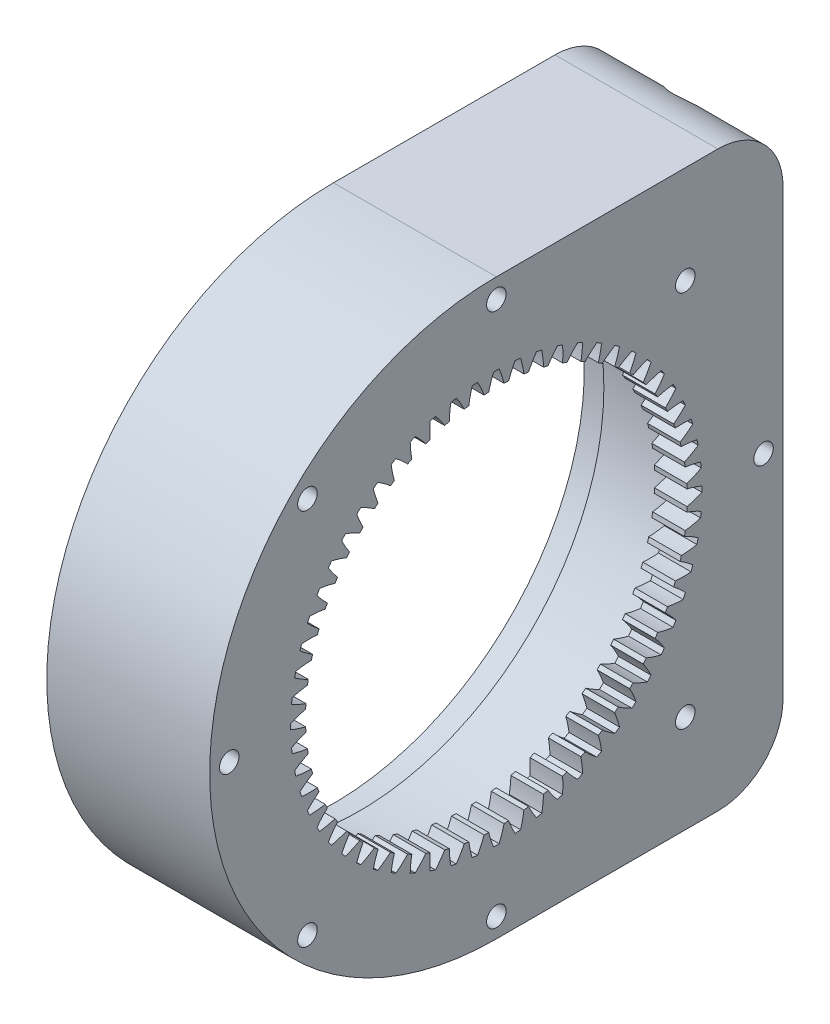
from build123d import *

# Parameters (mm, degrees)
BASPROSKE_W         = 5
BASPROSKE_H         = 14.71
TOOTHCUT_DEPTH      = 63.42595614
TEETHCUTS_COUNT     = 60
SKETCH4_R           = 44
SKETCH4_R_2         = 38.5
BOSS_EXTRUDE3_DEPTH = 20
BOSS_EXTRUDE5_DEPTH = 25
BOSS_EXTRUDE6_DEPTH = 25
FILLET1_R           = 10
SKETCH14_R          = 38.5
SKETCH14_R_2        = 37.5
BOSS_EXTRUDE7_DEPTH = 16
SKETCH15_R          = 1.5
CUT_EXTRUDE1_DEPTH  = 68.059674917
CIRPATTERN1_COUNT   = 8
SKETCH16_R          = 4.25
CUT_EXTRUDE2_DEPTH  = 20


with BuildPart() as part:
    # BasProSke → Base-Revolve (revolve)
    with BuildSketch(Plane(origin=(0, 0, 0), x_dir=(1, 0, 0), z_dir=(0, 1, 0)), mode=Mode.PRIVATE) as base_revolve_sk:
        with Locations((2.5, 36.645)):
            Rectangle(BASPROSKE_W, BASPROSKE_H)
    revolve(base_revolve_sk.sketch.rotate(Axis((-10, 0, 0), (1, 0, 0)), 180), axis=Axis((-10, 0, 0), (1, 0, 0)))

    # TooCutSke → ToothCut (cut, through all)
    with BuildSketch(Plane(origin=(0, 0, 0), x_dir=(0, 0, -1), z_dir=(1, 0, 0))):
        with BuildLine():
            ThreePointArc((1.17756088, 29.240898815), (0.846801732, 30.416008239), (0.422504134, 31.560672086))
            ThreePointArc((0.422504134, 31.560672086), (0, 31.5635), (-0.422504134, 31.560672086))
            ThreePointArc((-0.422504134, 31.560672086), (-0.846801732, 30.416008239), (-1.17756088, 29.240898815))
            ThreePointArc((-1.17756088, 29.240898815), (0, 29.2646), (1.17756088, 29.240898815))
        make_face()
    toothcut = extrude(amount=TOOTHCUT_DEPTH, mode=Mode.SUBTRACT)

    # TeethCuts: ToothCut ×60 about axis
    teethcuts_axis = Axis((0, 0, 0), (1, 0, 0))
    for i in range(1, TEETHCUTS_COUNT):
        add(toothcut.rotate(teethcuts_axis, i * 360 / TEETHCUTS_COUNT), mode=Mode.SUBTRACT)

    # Sketch4 → Boss-Extrude3 (add)
    with BuildSketch(Plane.ZY):
        Circle(SKETCH4_R)
        Circle(SKETCH4_R_2, mode=Mode.SUBTRACT)
    extrude(amount=BOSS_EXTRUDE3_DEPTH)

    # Sketch7 → Boss-Extrude5 (add)
    with BuildSketch(Plane(origin=(5, 0, 0), x_dir=(0, 0, -1), z_dir=(1, 0, 0))):
        with BuildLine():
            Line((0, 44), (44, 44))
            Line((44, 44), (44, 0))
            ThreePointArc((44, 0), (31.112698372, 31.112698372), (0, 44))
        make_face()
    extrude(amount=-BOSS_EXTRUDE5_DEPTH)

    # Sketch10 → Boss-Extrude6 (add)
    with BuildSketch(Plane(origin=(5, 0, 0), x_dir=(0, 0, -1), z_dir=(1, 0, 0))):
        with BuildLine():
            Line((0, -44), (44, -44))
            Line((44, -44), (44, 0))
            ThreePointArc((44, 0), (31.112698372, -31.112698372), (0, -44))
        make_face()
    extrude(amount=-BOSS_EXTRUDE6_DEPTH)

    # Fillet1
    fillet1_edges = [part.edges().sort_by_distance(p)[0] for p in [
        (-7.5, 44, -44),
        (-7.5, -44, -44),
    ]]
    fillet(fillet1_edges, radius=FILLET1_R)

    # Sketch14 → Boss-Extrude7 (add)
    with BuildSketch(Plane.ZY):
        Circle(SKETCH14_R)
        Circle(SKETCH14_R_2, mode=Mode.SUBTRACT)
    extrude(amount=BOSS_EXTRUDE7_DEPTH)

    # Sketch15 → Cut-Extrude1 (cut, through all)
    with BuildSketch(Plane.ZY.offset(20)):
        with Locations((-41, 0)):
            Circle(SKETCH15_R)
    cut_extrude1 = extrude(amount=-CUT_EXTRUDE1_DEPTH, mode=Mode.SUBTRACT)

    # CirPattern1: Cut-Extrude1 ×8 about axis
    cirpattern1_axis = Axis((0, 0, 0), (1, 0, 0))
    for i in range(1, CIRPATTERN1_COUNT):
        add(cut_extrude1.rotate(cirpattern1_axis, i * 360 / CIRPATTERN1_COUNT), mode=Mode.SUBTRACT)

    # Sketch16 → Cut-Extrude2 (cut)
    with BuildSketch(Plane(origin=(0, 0, -44), x_dir=(-1, 0, 0), z_dir=(0, 0, -1))):
        with Locations(Location((7.5, 38, 0), (0, 0, 90))):
            Circle(SKETCH16_R)
        with Locations(Location((7.5, -38, 0), (0, 0, 90))):
            Circle(SKETCH16_R)
    extrude(amount=-CUT_EXTRUDE2_DEPTH, mode=Mode.SUBTRACT)


solid = part.part
